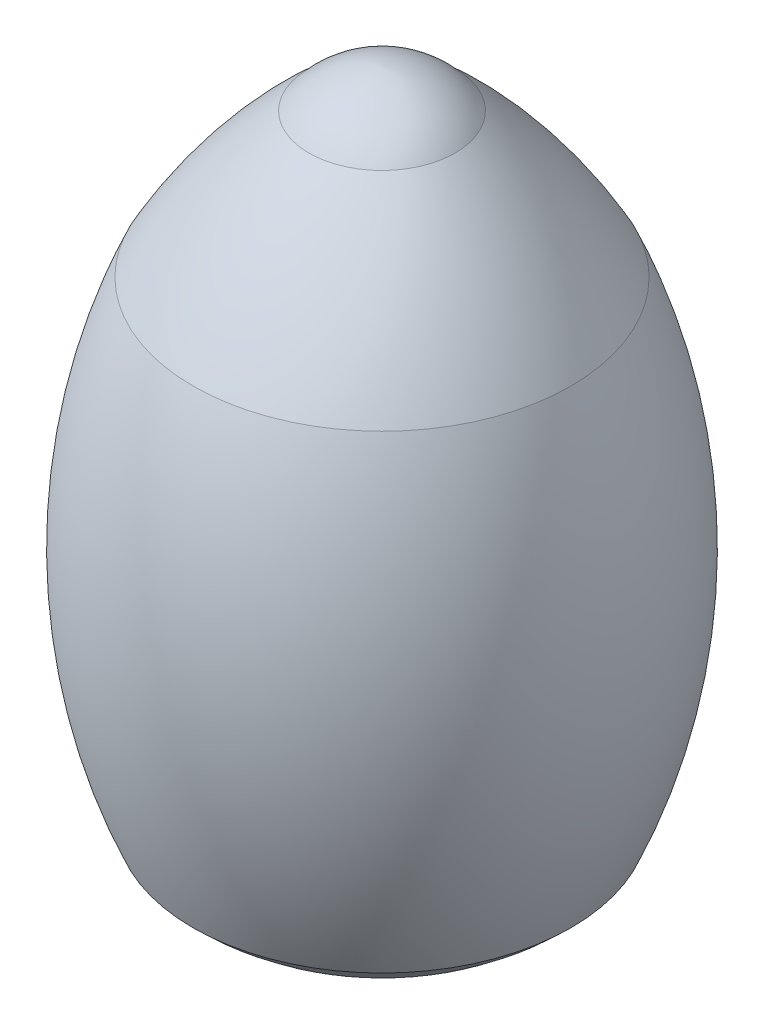
from build123d import *


with BuildPart() as part:
    # Sketch1 → Revolve1 (revolve)
    with BuildSketch(Plane.XY, mode=Mode.PRIVATE) as revolve1_sk:
        with BuildLine():
            Line((0, 0), (0, 500))
            ThreePointArc((0, 500), (-27.828906255, 492.245729459), (-50.365733017, 474.171765463))
            ThreePointArc((-50.365733017, 474.171765463), (-94.399484743, 427.996692658), (-130, 375.046603393))
            ThreePointArc((-130, 375.046603393), (-163.247689244, 213.549666817), (-130, 52.052730242))
            ThreePointArc((-130, 52.052730242), (-107.798812218, 33.404220706), (-82.644730745, 18.984379094))
            ThreePointArc((-82.644730745, 18.984379094), (-41.901275157, 6.972020566), (0, 0))
        make_face()
    revolve(revolve1_sk.sketch.rotate(Axis((0, 0, 0), (0, 1, 0)), 270), axis=Axis((0, 0, 0), (0, 1, 0)))  # turned: the seam where the file's is


solid = part.part
